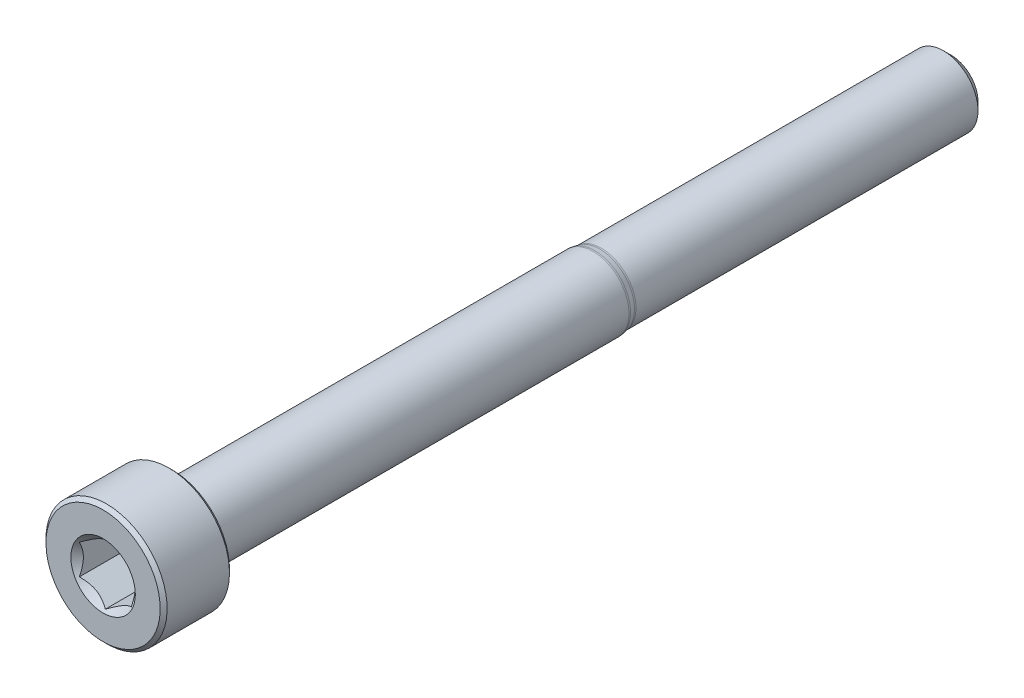
from build123d import *

# Parameters (mm, degrees)
CUT_EXTRUDE1_DEPTH = 3
SKETCH4_R          = 1.861954618
CUT_EXTRUDE2_DEPTH = 3
CUT_EXTRUDE2_DRAFT = -45


with BuildPart() as part:
    # Sketch2 → Revolve1 (revolve)
    with BuildSketch(Plane(origin=(0, 0, 0), x_dir=(0, 0, -1), z_dir=(1, 0, 0))):
        with BuildLine():
            Line((-24.5, 0), (-24.5, 3.3))
            Line((-24.5, 3.3), (-24.3, 3.5))
            Line((-24.3, 3.5), (-20.7, 3.5))
            Line((-20.7, 3.5), (-20.5, 3.3))
            Line((-20.5, 3.3), (-20.5, 2.275777223))
            ThreePointArc((-20.5, 2.275777223), (-20.441421356, 2.134355867), (-20.3, 2.075777223))
            Line((-20.3, 2.075777223), (3.807296473, 2.075777223))
            ThreePointArc((3.807296473, 2.075777223), (3.856305044, 2.073369586), (3.904841634, 2.066169863))
            Line((3.904841634, 2.066169863), (4.189200541, 2.00960736))
            ThreePointArc((4.189200541, 2.00960736), (4.237737132, 2.002407637), (4.286745702, 2))
            Line((4.286745702, 2), (24.045336663, 2))
            Line((24.045336663, 2), (24.5, 1.545336663))
            Line((24.5, 1.545336663), (24.5, 0))
            Line((24.5, 0), (-24.5, 0))
        make_face()
    revolve(axis=Axis((0, 0, -24.5), (0, 0, 1)))

    # Sketch3 → Cut-Extrude1 (cut)
    with BuildSketch(Plane.XY.offset(24.5)):
        Polygon((1.5, -0.866025404), (1.5, 0.866025404), (0, 1.732050808), (-1.5, 0.866025404), (-1.5, -0.866025404), (0, -1.732050808), align=None)
    extrude(amount=-CUT_EXTRUDE1_DEPTH, mode=Mode.SUBTRACT)


with BuildPart() as cut_extrude2_tool:
    # Sketch4 → Cut-Extrude2 (with draft: the straight prism first)
    with BuildSketch(Plane.XY.offset(24.5)):
        Circle(SKETCH4_R)
    extrude(amount=-CUT_EXTRUDE2_DEPTH)
    # Cut-Extrude2: the draft: its side faces are tilted about the plane it starts from
    cut_extrude2_sides = [cut_extrude2_tool.faces().sort_by_distance(p)[0] for p in [
        (-1.861954618, 0, 23),
    ]]
    draft(cut_extrude2_sides, Plane.XY.offset(24.5), CUT_EXTRUDE2_DRAFT)


with BuildPart() as part_1:
    add(part.part)

    # Cut-Extrude2: cut by cut_extrude2_tool
    add(cut_extrude2_tool.part, mode=Mode.SUBTRACT)


solid = part_1.part
